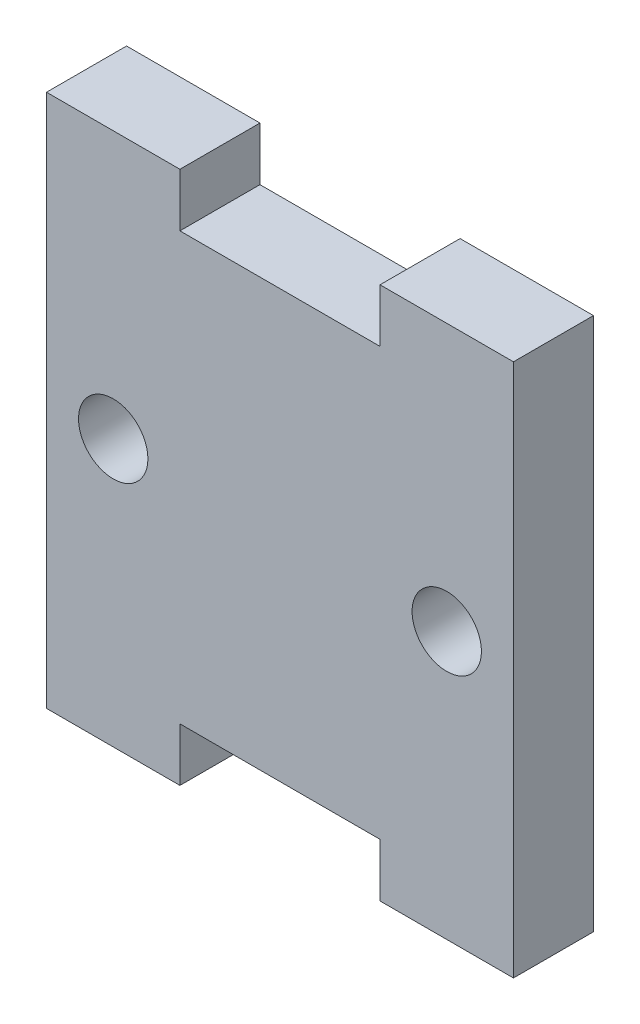
from build123d import *

# Parameters (mm, degrees)
ESBO_O1_W                = 10
ESBO_O1_H                = 4
ESBO_O1_W_2              = 35
ESBO_O1_H_2              = 32
ESBO_O1_R                = 2.6
RESSALTO_EXTRUS_O1_DEPTH = 6


with BuildPart() as part:
    # Esboço1 → Ressalto-extrusão1 (new body)
    with BuildSketch(Plane.XY):
        with Locations((-12.5, -18)):
            Rectangle(ESBO_O1_W, ESBO_O1_H)
        Rectangle(ESBO_O1_W_2, ESBO_O1_H_2)
        with Locations((-12.5, 0)):
            Circle(ESBO_O1_R, mode=Mode.SUBTRACT)
        with Locations((12.5, 0)):
            Circle(ESBO_O1_R, mode=Mode.SUBTRACT)
        with Locations((12.5, -18)):
            Rectangle(ESBO_O1_W, ESBO_O1_H)
        with Locations((12.5, 18)):
            Rectangle(ESBO_O1_W, ESBO_O1_H)
        with Locations((-12.5, 18)):
            Rectangle(ESBO_O1_W, ESBO_O1_H)
    extrude(amount=RESSALTO_EXTRUS_O1_DEPTH)


solid = part.part
